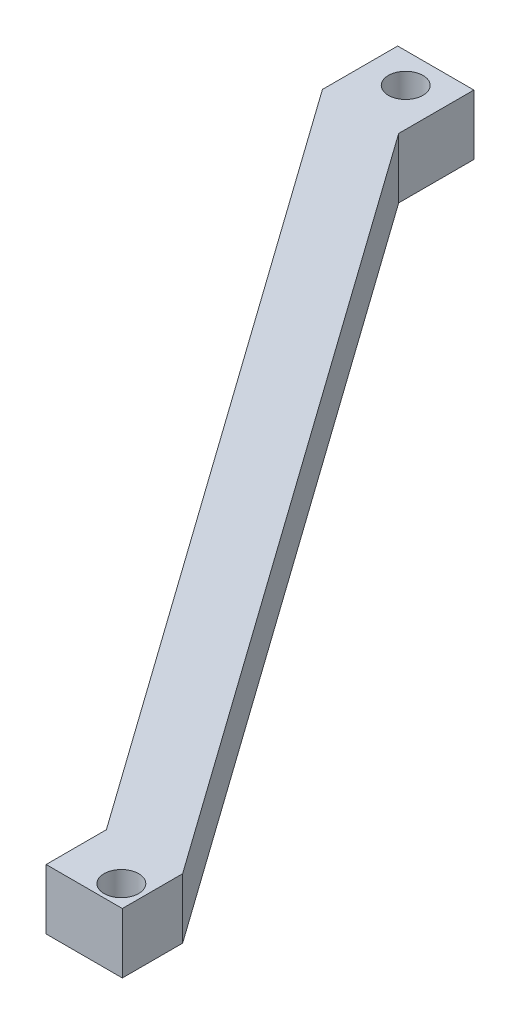
from build123d import *

# Parameters (mm, degrees)
BOSS_EXTRUDE2_DEPTH = 20
SKETCH3_R           = 5.75
CUT_EXTRUDE1_DEPTH  = 21


with BuildPart() as part:
    # Sketch2 → Boss-Extrude2 (new body)
    with BuildSketch(Plane(origin=(0, 0, 0), x_dir=(1, 0, 0), z_dir=(0, 1, 0))):
        Polygon((-12.666179626, 10), (-12.666179626, -15), (164.478056179, -263.93698429), (164.478056179, -283.967221838), (189.810415431, -283.967221838), (189.810415431, -263.93698429), (12.666179626, -15), (12.666179626, 10), align=None)
    extrude(amount=BOSS_EXTRUDE2_DEPTH)

    # Sketch3 → Cut-Extrude1 (cut, through all)
    with BuildSketch(Plane(origin=(0, 20, 0), x_dir=(1, 0, 0), z_dir=(0, 1, 0))):
        Circle(SKETCH3_R)
        with Locations((182.478056179, -276.967221838)):
            Circle(SKETCH3_R)
    extrude(amount=-CUT_EXTRUDE1_DEPTH, mode=Mode.SUBTRACT)


solid = part.part
